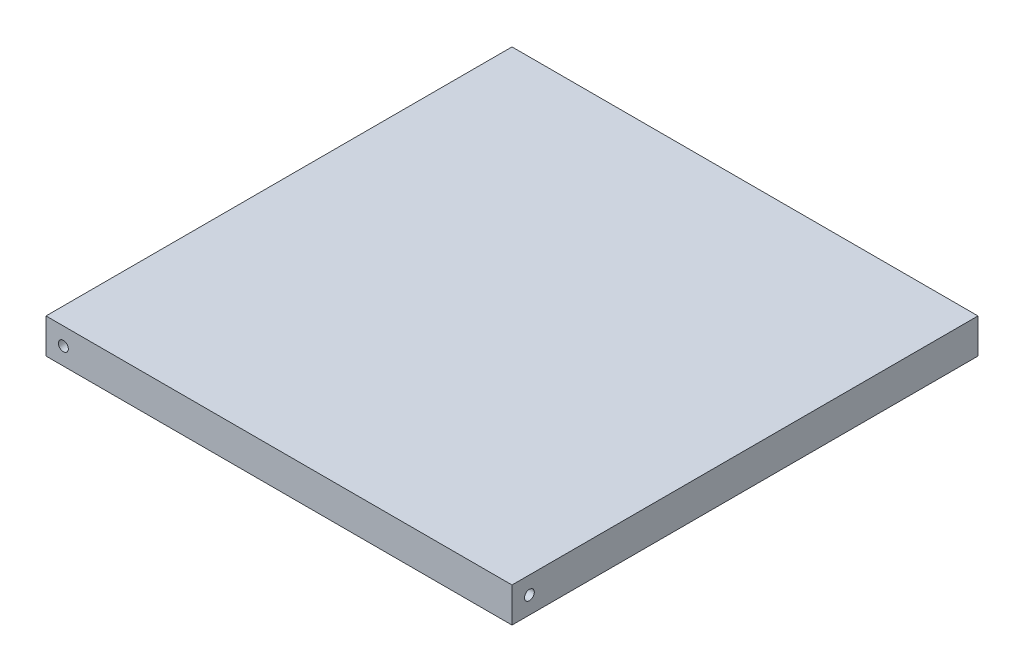
from build123d import *

# Parameters (mm, degrees)
SKETCH1_W           = 127.635
SKETCH1_H           = 127.635
BOSS_EXTRUDE1_DEPTH = 9.525
CIRPATTERN1_COUNT   = 4


with BuildPart() as part:
    # Sketch1 → Boss-Extrude1 (new body)
    with BuildSketch(Plane(origin=(0, 0, 0), x_dir=(1, 0, 0), z_dir=(0, 1, 0))):
        Rectangle(SKETCH1_W, SKETCH1_H)
    extrude(amount=BOSS_EXTRUDE1_DEPTH)

    # Sketch8 → Tap Drill for #6-32 Tap1 (revolve, cut)
    with BuildSketch(Plane(origin=(-59.055, 4.7625, 63.8175), x_dir=(0, -1, 0), z_dir=(1, 0, 0))):
        Polygon((0, 0), (0, 13.51269403), (1.35255, 12.7), (1.35255, 0), align=None)
    tap_drill_for_6_32_tap1 = revolve(axis=Axis((-59.055, 4.7625, 70.1675), (0, 0, -1)), mode=Mode.SUBTRACT)

    # CirPattern1: Tap Drill for #6-32 Tap1 ×4 about axis
    cirpattern1_axis = Axis((0, 9.525, 0), (0, -1, 0))
    for i in range(1, CIRPATTERN1_COUNT):
        add(tap_drill_for_6_32_tap1.rotate(cirpattern1_axis, i * 360 / CIRPATTERN1_COUNT), mode=Mode.SUBTRACT)


solid = part.part
